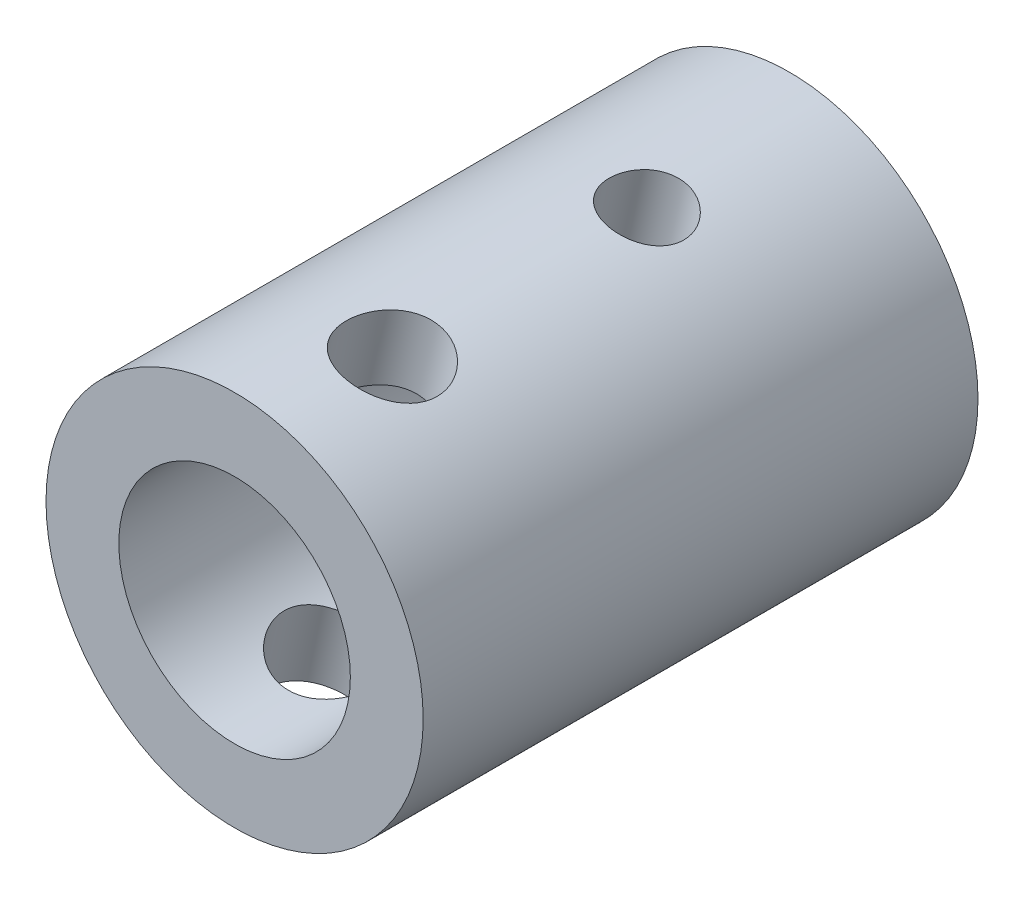
from build123d import *

# Parameters (mm, degrees)
SKETCH1_R                        = 25.9
BOSS_EXTRUDE1_DEPTH              = 76.2
SKETCH2_R                        = 15.9
CUT_EXTRUDE1_DEPTH               = 75
F_10_5_10_5_DIAMETER_HOLE1_D     = 10.5
F_10_5_10_5_DIAMETER_HOLE1_DEPTH = 20
F_10_5_10_5_DIAMETER_HOLE1_TIP   = 3.15451825
F_12_8_12_8_DIAMETER_HOLE1_D     = 12.8
F_12_8_12_8_DIAMETER_HOLE1_DEPTH = 300
F_12_8_12_8_DIAMETER_HOLE1_TIP   = 3.845507962


with BuildPart() as part:
    # Sketch1 → Boss-Extrude1 (new body)
    with BuildSketch(Plane.XY):
        Circle(SKETCH1_R)
    extrude(amount=BOSS_EXTRUDE1_DEPTH)

    # Sketch2 → Cut-Extrude1 (cut)
    with BuildSketch(Plane.XY.offset(76.2)):
        Circle(SKETCH2_R)
    extrude(amount=-CUT_EXTRUDE1_DEPTH, mode=Mode.SUBTRACT)

    # Ø10.5 (10.5) Diameter Hole1
    with Locations(Plane(origin=(5.482930922, 25.312990114, 25), x_dir=(0.977335526, -0.211696175, 0), z_dir=(0.211696175, 0.977335526, 0))):
        with Locations((0, 0)):
            Hole(F_10_5_10_5_DIAMETER_HOLE1_D / 2, depth=F_10_5_10_5_DIAMETER_HOLE1_DEPTH)
            with Locations((0, 0, -(F_10_5_10_5_DIAMETER_HOLE1_DEPTH + F_10_5_10_5_DIAMETER_HOLE1_TIP / 2))):  # 118° drill point
                Cone(0, F_10_5_10_5_DIAMETER_HOLE1_D / 2, F_10_5_10_5_DIAMETER_HOLE1_TIP, mode=Mode.SUBTRACT)

    # Ø12.8 (12.8) Diameter Hole1
    with Locations(Plane(origin=(5.555887044, 25.297073879, 60), x_dir=(0.976721125, -0.214513041, 0), z_dir=(0.214513041, 0.976721125, 0))):
        with Locations((0, 0)):
            Hole(F_12_8_12_8_DIAMETER_HOLE1_D / 2, depth=F_12_8_12_8_DIAMETER_HOLE1_DEPTH)
            with Locations((0, 0, -(F_12_8_12_8_DIAMETER_HOLE1_DEPTH + F_12_8_12_8_DIAMETER_HOLE1_TIP / 2))):  # 118° drill point
                Cone(0, F_12_8_12_8_DIAMETER_HOLE1_D / 2, F_12_8_12_8_DIAMETER_HOLE1_TIP, mode=Mode.SUBTRACT)


solid = part.part
